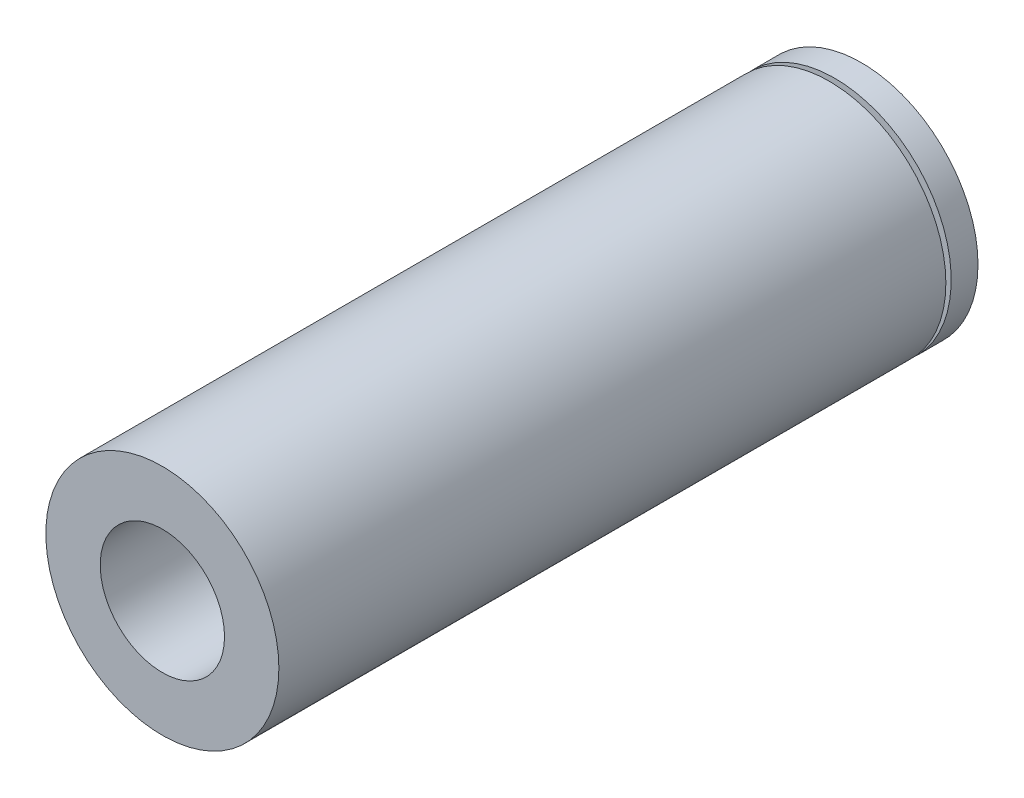
from build123d import *

# Parameters (mm, degrees)
SKETCH_1_R      = 7.5
SKETCH_1_R_2    = 4
EXTRUDE_1_DEPTH = 45
SKETCH_2_W      = 1.02813504
SKETCH_2_H      = 0.342481518
SKETCH_2_W_2    = 1.03
SKETCH_2_H_2    = 0.34


with BuildPart() as part:
    # 草图1 → 凸台-拉伸1 (new body)
    with BuildSketch(Plane.XY):
        Circle(SKETCH_1_R)
        Circle(SKETCH_1_R_2, mode=Mode.SUBTRACT)
    extrude(amount=EXTRUDE_1_DEPTH)

    # 草图2 → 切除-旋转1 (revolve, cut)
    with BuildSketch(Plane(origin=(0, 0, 0), x_dir=(1, 0, 0), z_dir=(0, 1, 0))):
        with Locations((7.5, -1.89679522)):
            Rectangle(SKETCH_2_W, SKETCH_2_H)
        with Locations((8.015, -43.1)):
            Rectangle(SKETCH_2_W_2, SKETCH_2_H_2)
    revolve(axis=Axis((0, 0, 0), (0, 0, -1)), mode=Mode.SUBTRACT)


solid = part.part
